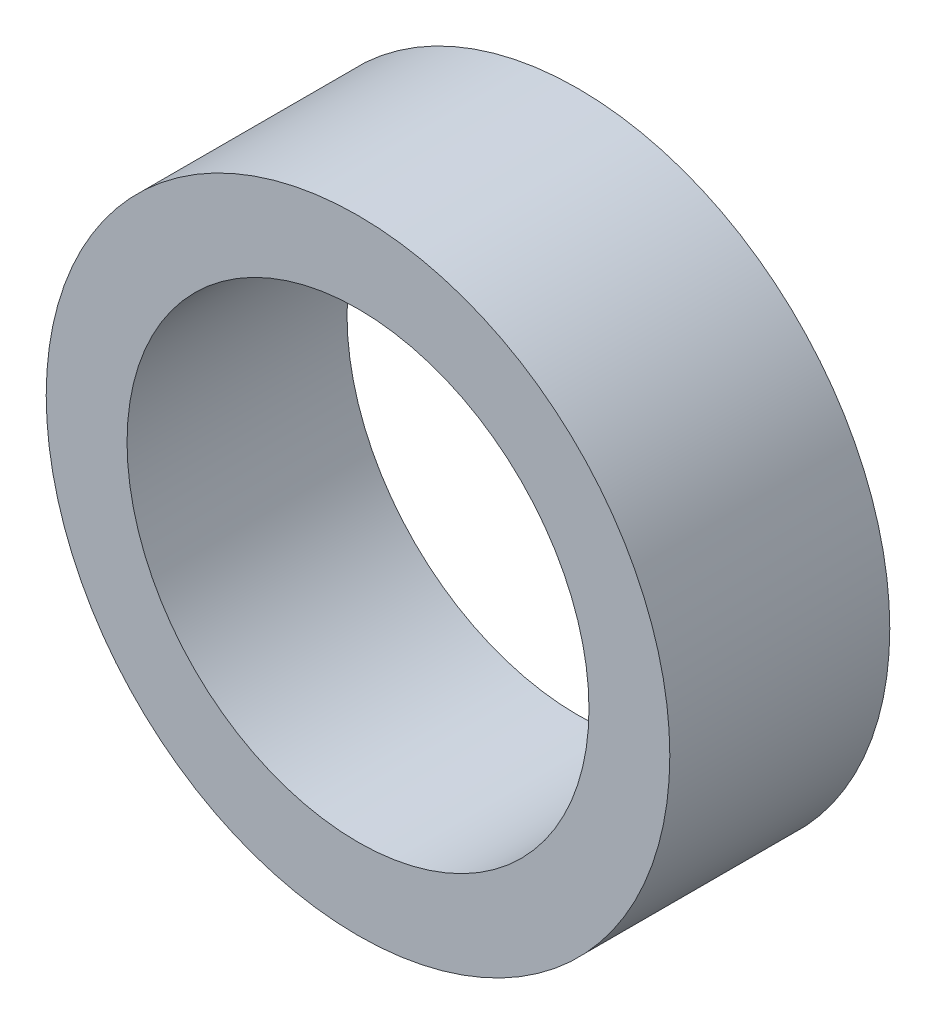
from build123d import *

# Parameters (mm, degrees)
SKETCH1_R           = 28.35
SKETCH1_R_2         = 21
BOSS_EXTRUDE1_DEPTH = 20


with BuildPart() as part:
    # Sketch1 → Boss-Extrude1 (new body)
    with BuildSketch(Plane.XY):
        Circle(SKETCH1_R)
        Circle(SKETCH1_R_2, mode=Mode.SUBTRACT)
    extrude(amount=BOSS_EXTRUDE1_DEPTH)


solid = part.part
